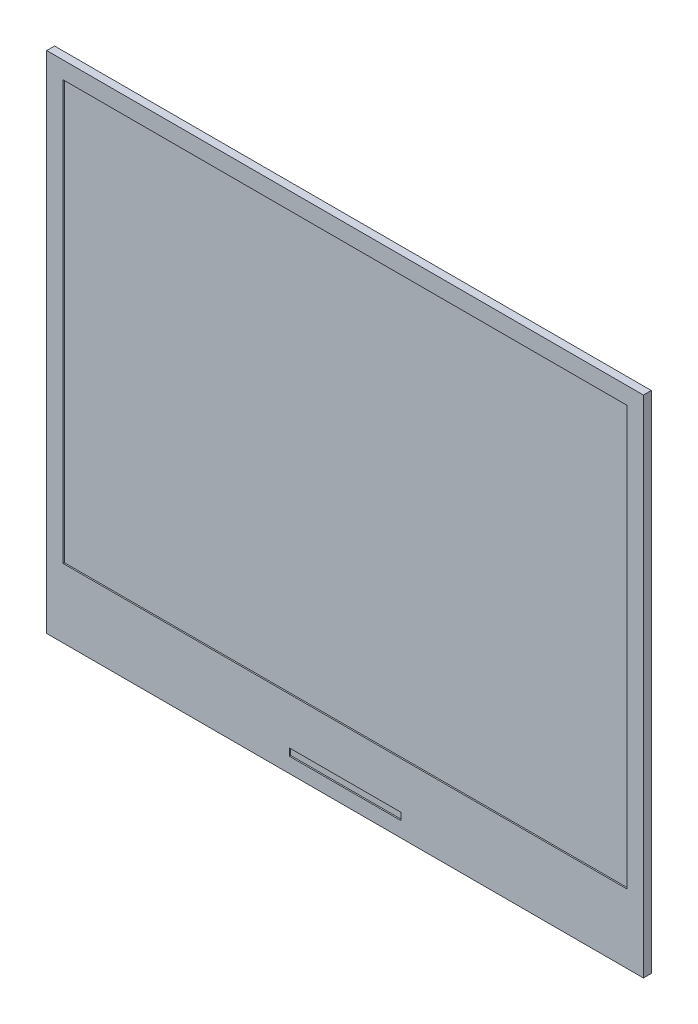
from build123d import *

# Parameters (mm, degrees)
ESQUISSE1_W             = 91
ESQUISSE1_H             = 77
BOSS_EXTRU_1_DEPTH      = 1.2
ESQUISSE2_W             = 85.996652656
ESQUISSE2_H             = 63.887239855
ENL_V_MAT_EXTRU_1_DEPTH = 0.2
ESQUISSE3_W             = 17.000934191
ESQUISSE3_H             = 1.101570178
ENL_V_MAT_EXTRU_2_DEPTH = 0.2


with BuildPart() as part:
    # Esquisse1 → Boss.-Extru.1 (new body)
    with BuildSketch(Plane.XY):
        with Locations((45.5, 38.5)):
            Rectangle(ESQUISSE1_W, ESQUISSE1_H)
    extrude(amount=BOSS_EXTRU_1_DEPTH)

    # Esquisse2 → Enlèv. mat.-Extru.1 (cut)
    with BuildSketch(Plane.XY.offset(1.2)):
        with Locations((45.498164964, 42.446254928)):
            Rectangle(ESQUISSE2_W, ESQUISSE2_H)
    extrude(amount=-ENL_V_MAT_EXTRU_1_DEPTH, mode=Mode.SUBTRACT)

    # Esquisse3 → Enlèv. mat.-Extru.2 (cut)
    with BuildSketch(Plane.XY.offset(1.2)):
        with Locations((45.496546397, 2.848297653)):
            Rectangle(ESQUISSE3_W, ESQUISSE3_H)
    extrude(amount=-ENL_V_MAT_EXTRU_2_DEPTH, mode=Mode.SUBTRACT)


solid = part.part
